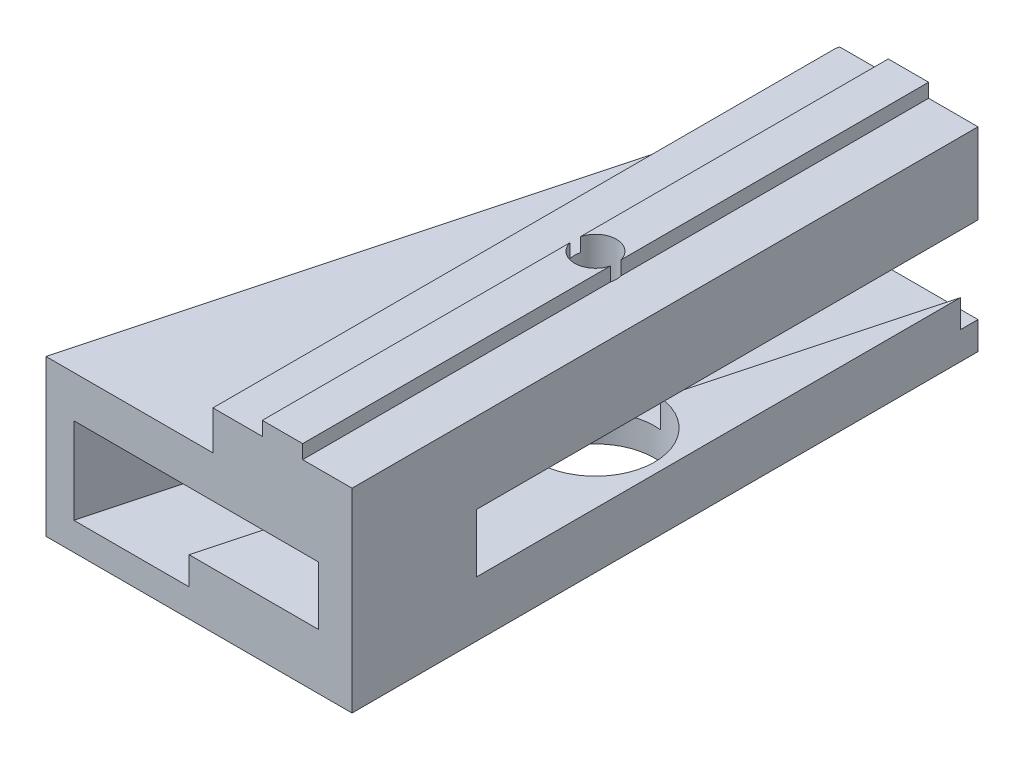
from build123d import *

# Parameters (mm, degrees)
MAKERBEAMFIX_DEPTH          = 22.5
SKETCH4_R                   = 1.5
FIXINGHOLE_DEPTH            = 16
SKETCH5_R                   = 4.25
DRIVERHOLE_DEPTH            = 12
HOLEFORCALIBERS_DEPTH       = 4.2
CUT_EXTRUDE2_DEPTH          = 16
SKETCH8_W                   = 12
SKETCH8_H                   = 2.8
CUT_EXTRUDE3_DEPTH          = 46
SKETCH9_W                   = 2
SKETCH9_H                   = 8
HOLEFORSCREWOFCALIBER_DEPTH = 49.643043085


with BuildPart() as part:
    # Sketch1 → MakerBeamFix (new body, symmetric)
    with BuildSketch(Plane.XY):
        Polygon((-11, 0), (11, 0), (11, 14), (7.45, 14), (7.45, 15), (4.55, 15), (4.55, 14), (-11, 14), align=None)
    extrude(amount=MAKERBEAMFIX_DEPTH, both=True)

    # Sketch4 → FixingHole (cut, through all)
    with BuildSketch(Plane.XZ):
        with Locations((6, 0)):
            Circle(SKETCH4_R)
    extrude(amount=-FIXINGHOLE_DEPTH, mode=Mode.SUBTRACT)

    # Sketch5 → DriverHole (cut, through all)
    with BuildSketch(Plane(origin=(0, 11, 0), x_dir=(1, 0, 0), z_dir=(0, 1, 0))):
        with Locations((6, 0)):
            Circle(SKETCH5_R)
    extrude(amount=-DRIVERHOLE_DEPTH, mode=Mode.SUBTRACT)

    # Sketch6 → HoleForCalibers (cut)
    with BuildSketch(Plane(origin=(0, 4, 0), x_dir=(1, 0, 0), z_dir=(0, 1, 0))):
        Polygon((7.420739047, -26.899923767), (-9, -22.5), (3.589745962, 24.485571585), (20.010485009, 20.085647818), align=None)
    extrude(amount=HOLEFORCALIBERS_DEPTH, mode=Mode.SUBTRACT)

    # Sketch7 → Cut-Extrude2 (cut, through all)
    with BuildSketch(Plane(origin=(0, 0, 0), x_dir=(-1, 0, 0), z_dir=(0, -1, 0))):
        Polygon((11, 22.5), (-1.057713659, 22.5), (11, -22.5), align=None)
    extrude(amount=-CUT_EXTRUDE2_DEPTH, mode=Mode.SUBTRACT)

    # Sketch8 → Cut-Extrude3 (cut, through all)
    with BuildSketch(Plane.XY.offset(22.5)):
        with Locations((-5, 12.6)):
            Rectangle(SKETCH8_W, SKETCH8_H)
    extrude(amount=-CUT_EXTRUDE3_DEPTH, mode=Mode.SUBTRACT)

    # Sketch9 → HoleForScrewOfCaliber (cut, through all)
    with BuildSketch(Plane(origin=(-6.227885683, 0, 23.242785793), x_dir=(0, -1, 0), z_dir=(-0.258819045, 0, 0.965925826))):
        with Locations((-3, 1.130096078)):
            Rectangle(SKETCH9_W, SKETCH9_H)
    extrude(amount=-HOLEFORSCREWOFCALIBER_DEPTH, mode=Mode.SUBTRACT)


solid = part.part
